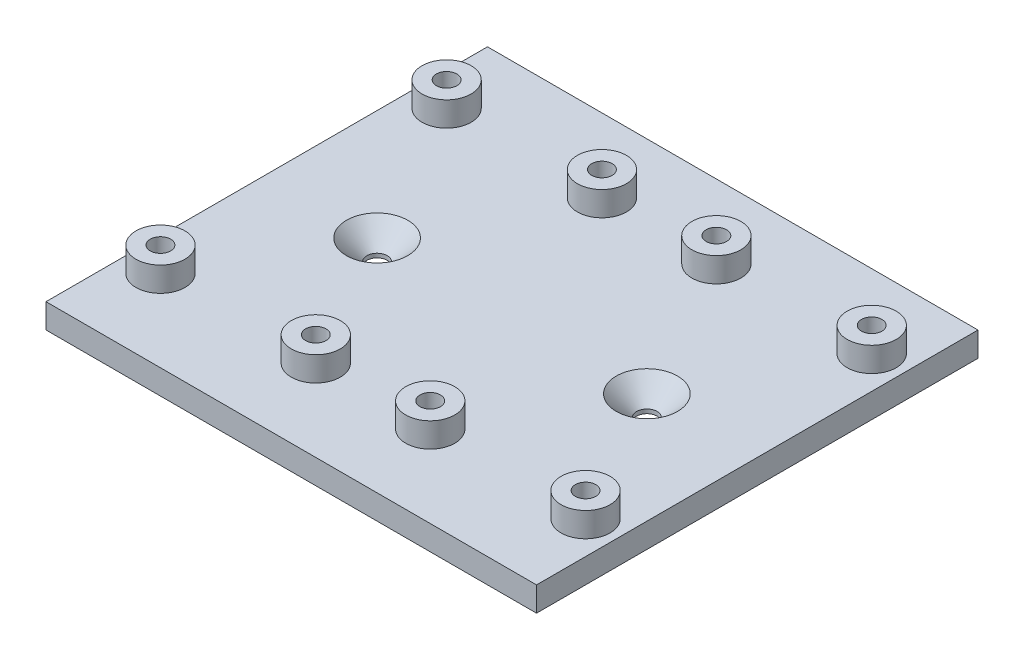
from build123d import *

# Parameters (mm, degrees)
SKETCH_1_W          = 60
SKETCH_1_H          = 54
EXTRUDE_1_DEPTH     = 3
SKETCH_3_R          = 3
SKETCH_3_R_2        = 1.25
EXTRUDE_2_DEPTH     = 3
SKETCH_4_R          = 1.25
CUT_EXTRUDE_1_DEPTH = 3
CHAMFER_1_SIZE      = 2.5


with BuildPart() as part:
    # Эскиз1 → Бобышка-Вытянуть1 (new body)
    with BuildSketch(Plane(origin=(0, 0, 0), x_dir=(1, 0, 0), z_dir=(0, 1, 0))):
        with Locations((-1.465707965, -0.838495575)):
            Rectangle(SKETCH_1_W, SKETCH_1_H)
    extrude(amount=-EXTRUDE_1_DEPTH)

    # Эскиз3 → Бобышка-Вытянуть2 (add)
    with BuildSketch(Plane(origin=(0, 0, 0), x_dir=(1, 0, 0), z_dir=(0, 1, 0))):
        with Locations((-27.465707965, 17.161504425)):
            Circle(SKETCH_3_R)
        with Locations((-27.465707965, 17.161504425)):
            Circle(SKETCH_3_R_2, mode=Mode.SUBTRACT)
        with Locations((-27.465707965, -17.838495575)):
            Circle(SKETCH_3_R)
        with Locations((-27.465707965, -17.838495575)):
            Circle(SKETCH_3_R_2, mode=Mode.SUBTRACT)
        with Locations((-8.465707965, 17.161504425)):
            Circle(SKETCH_3_R)
        with Locations((-8.465707965, 17.161504425)):
            Circle(SKETCH_3_R_2, mode=Mode.SUBTRACT)
        with Locations((-8.465707965, -17.838495575)):
            Circle(SKETCH_3_R)
        with Locations((-8.465707965, -17.838495575)):
            Circle(SKETCH_3_R_2, mode=Mode.SUBTRACT)
        with Locations((5.534292035, -17.838495575)):
            Circle(SKETCH_3_R)
        with Locations((5.534292035, -17.838495575)):
            Circle(SKETCH_3_R_2, mode=Mode.SUBTRACT)
        with Locations((5.534292035, 17.161504425)):
            Circle(SKETCH_3_R)
        with Locations((5.534292035, 17.161504425)):
            Circle(SKETCH_3_R_2, mode=Mode.SUBTRACT)
        with Locations((24.534292035, -17.838495575)):
            Circle(SKETCH_3_R)
        with Locations((24.534292035, -17.838495575)):
            Circle(SKETCH_3_R_2, mode=Mode.SUBTRACT)
        with Locations((24.534292035, 17.161504425)):
            Circle(SKETCH_3_R)
        with Locations((24.534292035, 17.161504425)):
            Circle(SKETCH_3_R_2, mode=Mode.SUBTRACT)
    extrude(amount=EXTRUDE_2_DEPTH)

    # Эскиз4 → Вырез-Вытянуть1 (cut)
    with BuildSketch(Plane(origin=(0, 0, 0), x_dir=(1, 0, 0), z_dir=(0, 1, 0))):
        with Locations((-17.965707965, -0.838495575)):
            Circle(SKETCH_4_R)
        with Locations((15.034292035, -0.838495575)):
            Circle(SKETCH_4_R)
    extrude(amount=-CUT_EXTRUDE_1_DEPTH, mode=Mode.SUBTRACT)

    # Фаска1
    chamfer_1_edges = [part.edges().sort_by_distance(p)[0] for p in [
        (-19.215707965, 0, 0.838495575),
        (13.784292035, 0, 0.838495575),
    ]]
    chamfer(chamfer_1_edges, length=CHAMFER_1_SIZE)


solid = part.part
